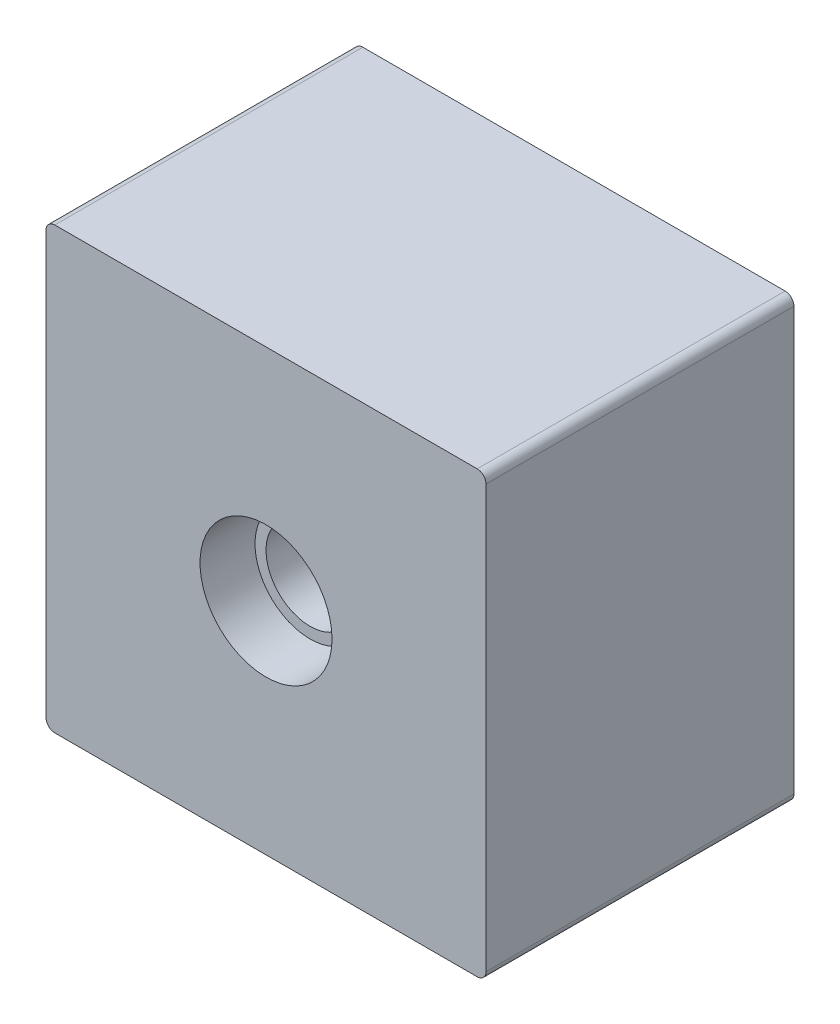
from build123d import *

# Parameters (mm, degrees)
SKETCH1_W           = 10
SKETCH1_H           = 10
BOSS_EXTRUDE1_DEPTH = 7
SKETCH2_R           = 1.5
CUT_EXTRUDE1_DEPTH  = 3
SKETCH3_R           = 1.25
SKETCH3_R_2         = 1
BOSS_EXTRUDE2_DEPTH = 2
FILLET1_R           = 0.2


with BuildPart() as part:
    # Sketch1 → Boss-Extrude1 (new body)
    with BuildSketch(Plane.XY):
        Rectangle(SKETCH1_W, SKETCH1_H)
    extrude(amount=BOSS_EXTRUDE1_DEPTH)

    # Sketch2 → Cut-Extrude1 (cut)
    with BuildSketch(Plane.XY.offset(7)):
        Circle(SKETCH2_R)
    extrude(amount=-CUT_EXTRUDE1_DEPTH, mode=Mode.SUBTRACT)

    # Sketch3 → Boss-Extrude2 (add)
    with BuildSketch(Plane.XY.offset(4)):
        Circle(SKETCH3_R)
        Circle(SKETCH3_R_2, mode=Mode.SUBTRACT)
    extrude(amount=BOSS_EXTRUDE2_DEPTH)

    # Fillet1
    fillet1_edges = [part.edges().sort_by_distance(p)[0] for p in [
        (-5, 5, 3.5),
        (5, 5, 3.5),
        (5, -5, 3.5),
        (-5, -5, 3.5),
    ]]
    fillet(fillet1_edges, radius=FILLET1_R)


solid = part.part
